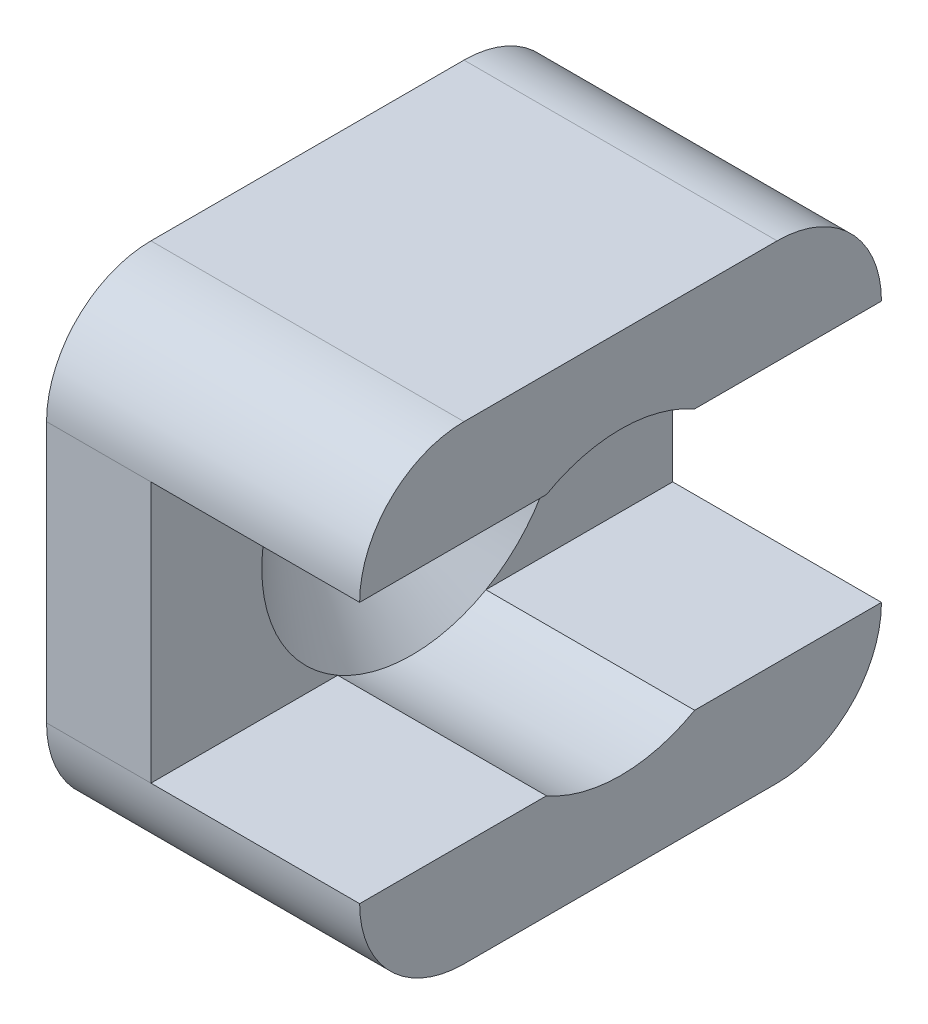
from build123d import *

# Parameters (mm, degrees)
ESQUISSE1_W             = 20
ESQUISSE1_H             = 18
BOSS_EXTRU_1_DEPTH      = 12
ESQUISSE2_W             = 8
ESQUISSE2_H             = 10
ENL_V_MAT_EXTRU_1_DEPTH = 21
ESQUISSE3_R             = 5.75
ENL_V_MAT_EXTRU_2_DEPTH = 8
CONG_2_R                = 4


with BuildPart() as part:
    # Esquisse1 → Boss.-Extru.1 (new body)
    with BuildSketch(Plane(origin=(8.078830023, 0, 0), x_dir=(0, 0, -1), z_dir=(1, 0, 0))):
        with Locations((-10, 10.8)):
            Rectangle(ESQUISSE1_W, ESQUISSE1_H)
    extrude(amount=-BOSS_EXTRU_1_DEPTH)

    # Esquisse2 → Enlèv. mat.-Extru.1 (cut, through all)
    with BuildSketch(Plane(origin=(0, 0, 0), x_dir=(-1, 0, 0), z_dir=(0, 0, -1))):
        with Locations((-4.078830023, 10.8)):
            Rectangle(ESQUISSE2_W, ESQUISSE2_H)
    extrude(amount=-ENL_V_MAT_EXTRU_1_DEPTH, mode=Mode.SUBTRACT)

    # Esquisse3 → Enlèv. mat.-Extru.2 (cut)
    with BuildSketch(Plane(origin=(8.078830023, 0, 0), x_dir=(0, 0, -1), z_dir=(1, 0, 0))):
        with Locations((-9.999999999, 10.8)):
            Circle(ESQUISSE3_R)
    extrude(amount=-ENL_V_MAT_EXTRU_2_DEPTH, mode=Mode.SUBTRACT)

    # Esquisse5 → Enlèvement de matière-Révolution1 (revolve, cut)
    with BuildSketch(Plane(origin=(0, 0, 10), x_dir=(-1, 0, 0), z_dir=(0, 0, -1)), mode=Mode.PRIVATE) as enl_vement_de_mati_re_r_volution1_sk:
        Polygon((-0.078830023, 16.55), (-0.078830023, 10.8), (3.921169977, 10.8), (3.921169977, 13.55), (2.921169977, 13.55), align=None)
    revolve(enl_vement_de_mati_re_r_volution1_sk.sketch.rotate(Axis((0.078830023, 10.8, 10), (-1, 0, 0)), 29.591845803), axis=Axis((0.078830023, 10.8, 10), (-1, 0, 0)), mode=Mode.SUBTRACT)  # turned: the seam where the file's is

    # Congé2
    cong_2_edges = [part.edges().sort_by_distance(p)[0] for p in [
        (2.078830023, 1.8, 20),
        (2.078830023, 19.8, 0),
        (2.078830023, 1.8, 0),
        (2.078830023, 19.8, 20),
    ]]
    fillet(cong_2_edges, radius=CONG_2_R)


solid = part.part
